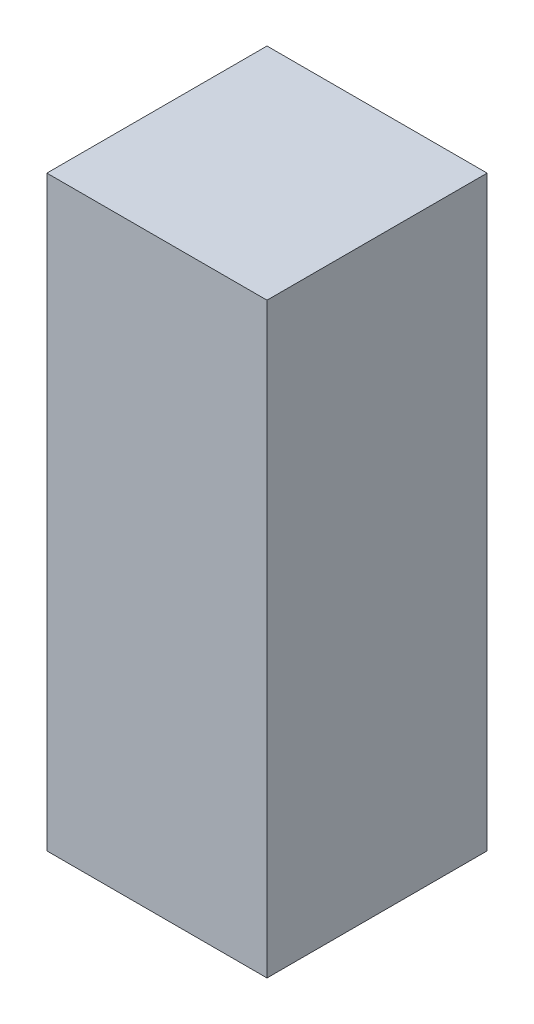
from build123d import *

# Parameters (mm, degrees)
SKETCH1_W           = 19.05
SKETCH1_H           = 19.05
BOSS_EXTRUDE1_DEPTH = 50.8


with BuildPart() as part:
    # Sketch1 → Boss-Extrude1 (new body)
    with BuildSketch(Plane(origin=(0, 0, 0), x_dir=(1, 0, 0), z_dir=(0, 1, 0))):
        Rectangle(SKETCH1_W, SKETCH1_H)
    extrude(amount=BOSS_EXTRUDE1_DEPTH)


solid = part.part
